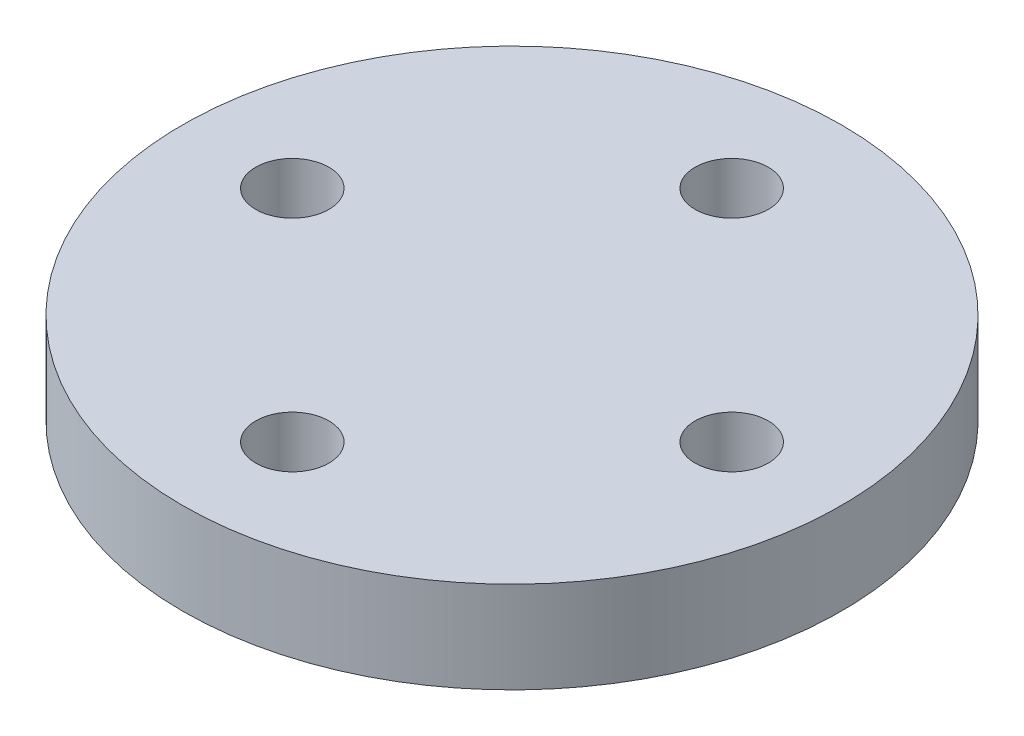
from build123d import *

# Parameters (mm, degrees)
SKETCH1_R           = 18
SKETCH1_R_2         = 2
BOSS_EXTRUDE1_DEPTH = 5


with BuildPart() as part:
    # Sketch1 → Boss-Extrude1 (new body)
    with BuildSketch(Plane(origin=(0, 0, 0), x_dir=(1, 0, 0), z_dir=(0, 1, 0))):
        Circle(SKETCH1_R)
        with Locations((-12, 0)):
            Circle(SKETCH1_R_2, mode=Mode.SUBTRACT)
        with Locations((0, -12)):
            Circle(SKETCH1_R_2, mode=Mode.SUBTRACT)
        with Locations((12, 0)):
            Circle(SKETCH1_R_2, mode=Mode.SUBTRACT)
        with Locations((0, 12)):
            Circle(SKETCH1_R_2, mode=Mode.SUBTRACT)
    extrude(amount=BOSS_EXTRUDE1_DEPTH)


solid = part.part
